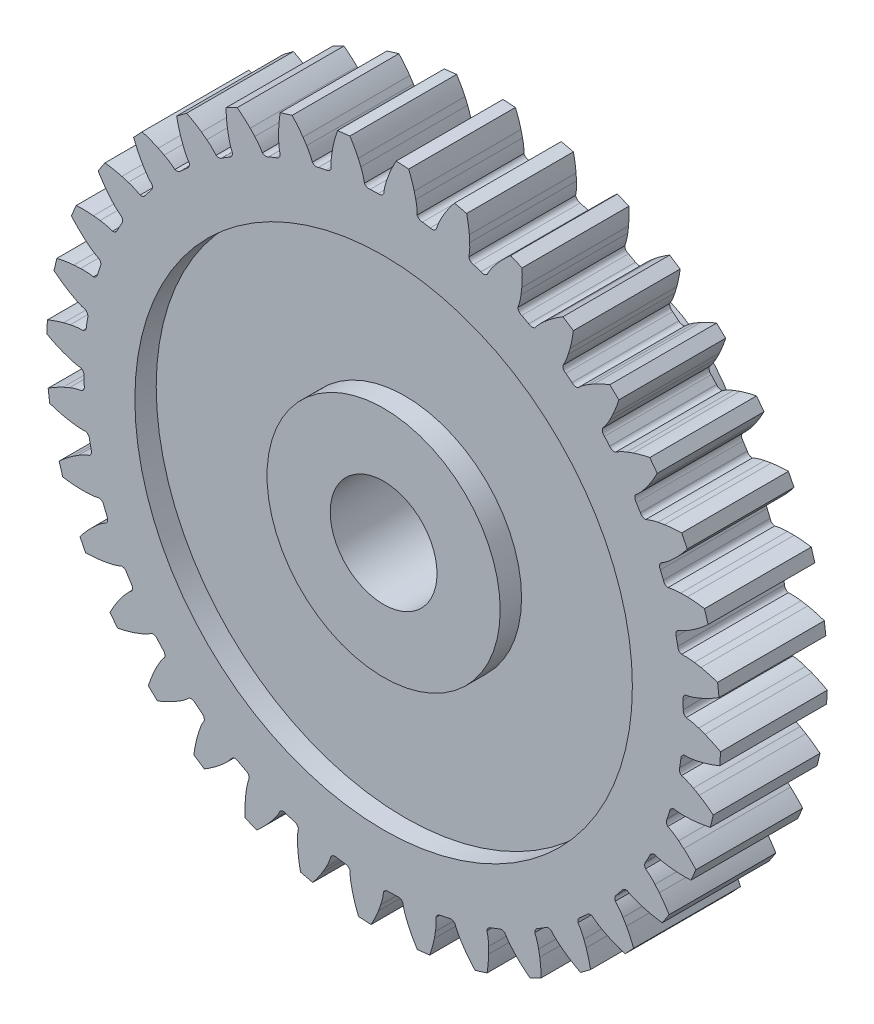
from build123d import *

# Parameters (mm, degrees)
MODEL_R             = 3.175
BOSS_EXTRUDE1_DEPTH = 6.35
SKETCH2_R           = 14.7955
SKETCH2_R_2         = 6.9342
CUT_EXTRUDE1_DEPTH  = 1.27
SKETCH3_R           = 14.7955
SKETCH3_R_2         = 7.62
CUT_EXTRUDE2_DEPTH  = 1.27
SKETCH4_R           = 7.62
SKETCH4_R_2         = 3.175
BOSS_EXTRUDE2_DEPTH = 7.62


with BuildPart() as part:
    # Model → Boss-Extrude1 (new body)
    with BuildSketch(Plane.XY):
        with BuildLine():
            Line((77.409149606, 88.38345564), (77.663315513, 88.690267015))
            ThreePointArc((77.663315513, 88.690267015), (78.015859422, 89.062022935), (78.39203915, 89.409842548))
            Line((78.39203915, 89.409842548), (79.073905257, 89.117654256))
            ThreePointArc((79.073905257, 89.117654256), (79.081524348, 88.605373453), (79.055509621, 88.09369689))
            Line((79.055509621, 88.09369689), (79.008657674, 87.698055906))
            ThreePointArc((79.008657674, 87.698055906), (78.940789963, 87.321747653), (78.828670449, 86.956175305))
            ThreePointArc((78.828670449, 86.956175305), (78.891320192, 86.770395671), (79.051204434, 86.656922803))
            Line((79.051204434, 86.656922803), (79.465600582, 86.434768475))
            ThreePointArc((79.465600582, 86.434768475), (79.648600627, 86.364421152), (79.837999893, 86.415073701))
            ThreePointArc((79.837999893, 86.415073701), (80.080401624, 86.71080376), (80.356239138, 86.975621684))
            Line((80.356239138, 86.975621684), (80.659815803, 87.233631048))
            ThreePointArc((80.659815803, 87.233631048), (81.071558515, 87.538520552), (81.50242147, 87.815733079))
            Line((81.50242147, 87.815733079), (82.123187177, 87.409579251))
            ThreePointArc((82.123187177, 87.409579251), (82.04173389, 86.903758104), (81.927262682, 86.404372467))
            Line((81.927262682, 86.404372467), (81.812425905, 86.022875741))
            ThreePointArc((81.812425905, 86.022875741), (81.680244015, 85.66406956), (81.506346876, 85.323520426))
            ThreePointArc((81.506346876, 85.323520426), (81.535786454, 85.12968568), (81.673537008, 84.990174454))
            Line((81.673537008, 84.990174454), (82.043052695, 84.699443515))
            ThreePointArc((82.043052695, 84.699443515), (82.211056874, 84.598387303), (82.406374462, 84.615381488))
            ThreePointArc((82.406374462, 84.615381488), (82.696446375, 84.864525792), (83.014078181, 85.077421622))
            Line((83.014078181, 85.077421622), (83.357840946, 85.27879979))
            ThreePointArc((83.357840946, 85.27879979), (83.816271868, 85.507558967), (84.288726497, 85.705741445))
            Line((84.288726497, 85.705741445), (84.829538787, 85.197958355))
            ThreePointArc((84.829538787, 85.197958355), (84.661488037, 84.713965983), (84.462038499, 84.242044852))
            Line((84.462038499, 84.242044852), (84.28270218, 83.886283232))
            ThreePointArc((84.28270218, 83.886283232), (84.090222391, 83.555881268), (83.859831404, 83.250702762))
            ThreePointArc((83.859831404, 83.250702762), (83.855166085, 83.054703598), (83.966596713, 82.893394416))
            Line((83.966596713, 82.893394416), (84.280018083, 82.542909385))
            ThreePointArc((84.280018083, 82.542909385), (84.427921674, 82.414214824), (84.623222958, 82.397034286))
            ThreePointArc((84.623222958, 82.397034286), (84.952151367, 82.592023042), (85.301926498, 82.746528287))
            Line((85.301926498, 82.746528287), (85.675439791, 82.885146559))
            ThreePointArc((85.675439791, 82.885146559), (86.166629732, 83.030824676), (86.666320739, 83.143955432))
            Line((86.666320739, 83.143955432), (87.110743193, 82.549979254))
            ThreePointArc((87.110743193, 82.549979254), (86.861201118, 82.10252152), (86.582833422, 81.672403981))
            Line((86.582833422, 81.672403981), (86.344435763, 81.353194507))
            ThreePointArc((86.344435763, 81.353194507), (86.097506475, 81.061235856), (85.817621954, 80.800700672))
            ThreePointArc((85.817621954, 80.800700672), (85.778990261, 80.608488118), (85.86071701, 80.430278095))
            Line((85.86071701, 80.430278095), (86.108518935, 80.030689944))
            ThreePointArc((86.108518935, 80.030689944), (86.231827962, 79.878267353), (86.421178811, 79.827434114))
            ThreePointArc((86.421178811, 79.827434114), (86.778968066, 79.962341881), (87.150257308, 80.053761542))
            Line((87.150257308, 80.053761542), (87.542169294, 80.125416917))
            ThreePointArc((87.542169294, 80.125416917), (88.051193695, 80.183587618), (88.562938223, 80.208229231))
            Line((88.562938223, 80.208229231), (88.897463323, 79.546103807))
            ThreePointArc((88.897463323, 79.546103807), (88.574012133, 79.148776488), (88.225184341, 78.773531444))
            Line((88.225184341, 78.773531444), (87.934983527, 78.50056402))
            ThreePointArc((87.934983527, 78.50056402), (87.641107562, 78.255919697), (87.320233656, 78.047944066))
            ThreePointArc((87.320233656, 78.047944066), (87.248813985, 77.865361877), (87.298353121, 77.675670289))
            Line((87.298353121, 77.675670289), (87.472999665, 77.239120879))
            ThreePointArc((87.472999665, 77.239120879), (87.567967446, 77.067601541), (87.745614531, 76.984660144))
            ThreePointArc((87.745614531, 76.984660144), (88.121396047, 77.055389462), (88.502920894, 77.080946748))
            Line((88.502920894, 77.080946748), (88.901325878, 77.083459706))
            ThreePointArc((88.901325878, 77.083459706), (89.41271829, 77.052355503), (89.92096724, 76.98775925))
            Line((89.92096724, 76.98775925), (90.135431937, 76.277603103))
            ThreePointArc((90.135431937, 76.277603103), (89.747899533, 75.942478788), (89.339210601, 75.63350787))
            Line((89.339210601, 75.63350787), (89.006015131, 75.415078001))
            ThreePointArc((89.006015131, 75.415078001), (88.674121761, 75.225181402), (88.322008061, 75.076084556))
            ThreePointArc((88.322008061, 75.076084556), (88.219971208, 74.908678426), (88.235818745, 74.71326812))
            Line((88.235818745, 74.71326812), (88.332002701, 74.253025985))
            ThreePointArc((88.332002701, 74.253025985), (88.395743688, 74.06762143), (88.556289293, 73.955092005))
            ThreePointArc((88.556289293, 73.955092005), (88.938644666, 73.959493121), (89.318812075, 73.918410986))
            Line((89.318812075, 73.918410986), (89.711596255, 73.851701439))
            ThreePointArc((89.711596255, 73.851701439), (90.20981828, 73.732267418), (90.699128765, 73.580396023))
            Line((90.699128765, 73.580396023), (90.787018694, 72.843792907))
            ThreePointArc((90.787018694, 72.843792907), (90.347180051, 72.58105418), (89.891047785, 72.347745312))
            Line((89.891047785, 72.347745312), (89.524986363, 72.190494357))
            ThreePointArc((89.524986363, 72.190494357), (89.165160001, 72.061115393), (88.792505304, 71.975427566))
            ThreePointArc((88.792505304, 71.975427566), (88.662943162, 71.828281525), (88.644615781, 71.63308313))
            Line((88.644615781, 71.63308313), (88.659423778, 71.163134507))
            ThreePointArc((88.659423778, 71.163134507), (88.690003504, 70.969490709), (88.828558454, 70.830798367))
            ThreePointArc((88.828558454, 70.830798367), (89.205867913, 70.768737275), (89.573124616, 70.662264176))
            Line((89.573124616, 70.662264176), (89.948356656, 70.528365369))
            ThreePointArc((89.948356656, 70.528365369), (90.418270069, 70.324230473), (90.873774637, 70.089698471))
            Line((90.873774637, 70.089698471), (90.83242255, 69.349015729))
            ThreePointArc((90.83242255, 69.349015729), (90.353641943, 69.166645771), (89.863925692, 69.016087927))
            Line((89.863925692, 69.016087927), (89.47612149, 68.924792014))
            ThreePointArc((89.47612149, 68.924792014), (89.099295278, 68.859861798), (88.717422507, 68.840186571))
            ThreePointArc((88.717422507, 68.840186571), (88.564275546, 68.717775768), (88.512330004, 68.528725359))
            Line((88.512330004, 68.528725359), (88.44531154, 68.063340247))
            ThreePointArc((88.44531154, 68.063340247), (88.441796382, 67.867316253), (88.554172572, 67.706663353))
            ThreePointArc((88.554172572, 67.706663353), (88.914969915, 67.580026485), (89.258155416, 67.411398694))
            Line((89.258155416, 67.411398694), (89.604438768, 67.214379509))
            ThreePointArc((89.604438768, 67.214379509), (90.031765488, 66.931746273), (90.439623863, 66.621679801))
            Line((90.439623863, 66.621679801), (90.270280006, 65.899432014))
            ThreePointArc((90.270280006, 65.899432014), (89.767104941, 65.802972046), (89.258684485, 65.739739848))
            Line((89.258684485, 65.739739848), (88.860918298, 65.717173697))
            ThreePointArc((88.860918298, 65.717173697), (88.478541909, 65.718665102), (88.099054076, 65.765600297))
            ThreePointArc((88.099054076, 65.765600297), (87.926979225, 65.671641448), (87.842995655, 65.494483948))
            Line((87.842995655, 65.494483948), (87.696174889, 65.047814961))
            ThreePointArc((87.696174889, 65.047814961), (87.658673925, 64.855379413), (87.741445785, 64.677653271))
            ThreePointArc((87.741445785, 64.677653271), (88.074775852, 64.490287008), (88.383469465, 64.264625086))
            Line((88.383469465, 64.264625086), (88.690280841, 64.010466808))
            ThreePointArc((88.690280841, 64.010466808), (89.06203676, 63.657922899), (89.409856373, 63.281743171))
            Line((89.409856373, 63.281743171), (89.117668081, 62.599873249))
            ThreePointArc((89.117668081, 62.599873249), (88.605387279, 62.592254158), (88.093710716, 62.618268885))
            Line((88.093710716, 62.618268885), (87.698069731, 62.665120833))
            ThreePointArc((87.698069731, 62.665120833), (87.321761479, 62.732988543), (86.95618913, 62.845108057))
            ThreePointArc((86.95618913, 62.845108057), (86.770409496, 62.782458314), (86.656936629, 62.622574072))
            Line((86.656936629, 62.622574072), (86.4347823, 62.208181739))
            ThreePointArc((86.4347823, 62.208181739), (86.364434977, 62.025181693), (86.415087526, 61.835782428))
            ThreePointArc((86.415087526, 61.835782428), (86.710818718, 61.593380027), (86.975637591, 61.31754162))
            Line((86.975637591, 61.31754162), (87.233646955, 61.01396877))
            ThreePointArc((87.233646955, 61.01396877), (87.53853646, 60.602226058), (87.815748986, 60.171363103))
            Line((87.815748986, 60.171363103), (87.409595158, 59.550593581))
            ThreePointArc((87.409595158, 59.550593581), (86.903774011, 59.632046869), (86.404388374, 59.746518076))
            Line((86.404388374, 59.746518076), (86.022891648, 59.861354854))
            ThreePointArc((86.022891648, 59.861354854), (85.664085468, 59.993536744), (85.323536334, 60.167433882))
            ThreePointArc((85.323536334, 60.167433882), (85.129702403, 60.137994719), (84.990191727, 60.000244843))
            Line((84.990191727, 60.000244843), (84.699460788, 59.630725342))
            ThreePointArc((84.699460788, 59.630725342), (84.598404575, 59.462721162), (84.61539876, 59.267403575))
            ThreePointArc((84.61539876, 59.267403575), (84.864543064, 58.977331662), (85.077438894, 58.659699856))
            Line((85.077438894, 58.659699856), (85.278817063, 58.315933276))
            ThreePointArc((85.278817063, 58.315933276), (85.507576239, 57.857502354), (85.705758718, 57.385047725))
            Line((85.705758718, 57.385047725), (85.197975628, 56.84423925))
            ThreePointArc((85.197975628, 56.84423925), (84.713983255, 57.012289999), (84.242062125, 57.211739537))
            Line((84.242062125, 57.211739537), (83.886300504, 57.391075856))
            ThreePointArc((83.886300504, 57.391075856), (83.55589854, 57.583555645), (83.250720034, 57.813946632))
            ThreePointArc((83.250720034, 57.813946632), (83.054721395, 57.818612526), (82.893412522, 57.707182348))
            Line((82.893412522, 57.707182348), (82.542927491, 57.393760979))
            ThreePointArc((82.542927491, 57.393760979), (82.41423293, 57.245857388), (82.397052392, 57.050556103))
            ThreePointArc((82.397052392, 57.050556103), (82.592041148, 56.721627695), (82.746546393, 56.371852564))
            Line((82.746546393, 56.371852564), (82.885164665, 55.99833927))
            ThreePointArc((82.885164665, 55.99833927), (83.030842782, 55.50714933), (83.143973538, 55.007458322))
            Line((83.143973538, 55.007458322), (82.54999736, 54.563035869))
            ThreePointArc((82.54999736, 54.563035869), (82.102539626, 54.812577943), (81.672422087, 55.090945639))
            Line((81.672422087, 55.090945639), (81.353212613, 55.329339483))
            ThreePointArc((81.353212613, 55.329339483), (81.061253962, 55.576268771), (80.800718778, 55.856153293))
            ThreePointArc((80.800718778, 55.856153293), (80.608505918, 55.894784163), (80.43029589, 55.813057093))
            Line((80.43029589, 55.813057093), (80.03070774, 55.565258984))
            ThreePointArc((80.03070774, 55.565258984), (79.878285149, 55.441949957), (79.82745191, 55.252599107))
            ThreePointArc((79.82745191, 55.252599107), (79.962359676, 54.894809852), (80.053779338, 54.52352061))
            Line((80.053779338, 54.52352061), (80.125434713, 54.131608624))
            ThreePointArc((80.125434713, 54.131608624), (80.183605413, 53.622584223), (80.208247026, 53.110839695))
            Line((80.208247026, 53.110839695), (79.546121602, 52.776310781))
            ThreePointArc((79.546121602, 52.776310781), (79.148794283, 53.099761971), (78.773549239, 53.448589762))
            Line((78.773549239, 53.448589762), (78.500581815, 53.738794391))
            ThreePointArc((78.500581815, 53.738794391), (78.255937493, 54.032670356), (78.047961861, 54.353544262))
            ThreePointArc((78.047961861, 54.353544262), (77.865379487, 54.424962802), (77.675688224, 54.375423364))
            Line((77.675688224, 54.375423364), (77.239138814, 54.20077682))
            ThreePointArc((77.239138814, 54.20077682), (77.067619477, 54.10580904), (76.984678079, 53.928161954))
            ThreePointArc((76.984678079, 53.928161954), (77.055406721, 53.552382247), (77.08096377, 53.17085929))
            Line((77.08096377, 53.17085929), (77.083476728, 52.772458121))
            ThreePointArc((77.083476728, 52.772458121), (77.052372525, 52.261065708), (76.987776272, 51.752816758))
            Line((76.987776272, 51.752816758), (76.277620124, 51.538348247))
            ThreePointArc((76.277620124, 51.538348247), (75.942495809, 51.925880651), (75.633524891, 52.334569583))
            Line((75.633524891, 52.334569583), (75.415095023, 52.667761238))
            ThreePointArc((75.415095023, 52.667761238), (75.225198423, 52.999654608), (75.076101578, 53.351768308))
            ThreePointArc((75.076101578, 53.351768308), (74.908695626, 53.453806624), (74.713284677, 53.437959483))
            Line((74.713284677, 53.437959483), (74.253042542, 53.341771712))
            ThreePointArc((74.253042542, 53.341771712), (74.067637987, 53.278030726), (73.955108562, 53.117485121))
            ThreePointArc((73.955108562, 53.117485121), (73.959509316, 52.73513166), (73.918427274, 52.354966166))
            Line((73.918427274, 52.354966166), (73.851717727, 51.962181986))
            ThreePointArc((73.851717727, 51.962181986), (73.732283707, 51.463959962), (73.580412312, 50.974649477))
            Line((73.580412312, 50.974649477), (72.843809196, 50.886755733))
            ThreePointArc((72.843809196, 50.886755733), (72.581070468, 51.326594376), (72.347761601, 51.782726642))
            Line((72.347761601, 51.782726642), (72.190510646, 52.148788064))
            ThreePointArc((72.190510646, 52.148788064), (72.061131681, 52.508614426), (71.975443854, 52.881269123))
            ThreePointArc((71.975443854, 52.881269123), (71.828298098, 53.010833042), (71.633098795, 53.029161016))
            Line((71.633098795, 53.029161016), (71.163150171, 53.01435302))
            ThreePointArc((71.163150171, 53.01435302), (70.969493822, 52.983775565), (70.830795521, 52.845209538))
            ThreePointArc((70.830795521, 52.845209538), (70.768734429, 52.467900079), (70.66226133, 52.100643376))
            Line((70.66226133, 52.100643376), (70.528362523, 51.725411336))
            ThreePointArc((70.528362523, 51.725411336), (70.324227626, 51.255497923), (70.089695625, 50.799993355))
            Line((70.089695625, 50.799993355), (69.349012882, 50.841345442))
            ThreePointArc((69.349012882, 50.841345442), (69.166642925, 51.320126049), (69.01608508, 51.8098423))
            Line((69.01608508, 51.8098423), (68.924789168, 52.197650317))
            ThreePointArc((68.924789168, 52.197650317), (68.859858952, 52.574476529), (68.840183725, 52.9563493))
            ThreePointArc((68.840183725, 52.9563493), (68.717771938, 53.109492192), (68.528723709, 53.16143599))
            Line((68.528723709, 53.16143599), (68.063338597, 53.228462084))
            ThreePointArc((68.063338597, 53.228462084), (67.867314603, 53.231977242), (67.706661703, 53.119601052))
            ThreePointArc((67.706661703, 53.119601052), (67.580027832, 52.758800249), (67.411402349, 52.415611084))
            Line((67.411402349, 52.415611084), (67.214375942, 52.06932803))
            ThreePointArc((67.214375942, 52.06932803), (66.931742706, 51.642001311), (66.621676234, 51.234142935))
            Line((66.621676234, 51.234142935), (65.899428447, 51.403486792))
            ThreePointArc((65.899428447, 51.403486792), (65.802968479, 51.906661857), (65.739736281, 52.415082313))
            Line((65.739736281, 52.415082313), (65.71717013, 52.812852315))
            ThreePointArc((65.71717013, 52.812852315), (65.718661536, 53.195228704), (65.76559673, 53.574716537))
            ThreePointArc((65.76559673, 53.574716537), (65.671637106, 53.746789182), (65.494480772, 53.830771558))
            Line((65.494480772, 53.830771558), (65.047811786, 53.977592324))
            ThreePointArc((65.047811786, 53.977592324), (64.855376237, 54.015093288), (64.677650095, 53.932321428))
            ThreePointArc((64.677650095, 53.932321428), (64.490284355, 53.598992917), (64.264623303, 53.290300666))
            Line((64.264623303, 53.290300666), (64.010465025, 52.98348929))
            ThreePointArc((64.010465025, 52.98348929), (63.657921116, 52.611733371), (63.281741387, 52.263913758))
            Line((63.281741387, 52.263913758), (62.599871466, 52.55610205))
            ThreePointArc((62.599871466, 52.55610205), (62.592252375, 53.068382852), (62.618267102, 53.580059416))
            Line((62.618267102, 53.580059416), (62.66511905, 53.975704214))
            ThreePointArc((62.66511905, 53.975704214), (62.73298676, 54.352012467), (62.845106274, 54.717584816))
            ThreePointArc((62.845106274, 54.717584816), (62.782454331, 54.903359907), (62.622572344, 55.016829729))
            Line((62.622572344, 55.016829729), (62.208180011, 55.238984058))
            ThreePointArc((62.208180011, 55.238984058), (62.025179965, 55.30933138), (61.8357807, 55.258678831))
            ThreePointArc((61.8357807, 55.258678831), (61.593378978, 54.962948904), (61.317541524, 54.698131072))
            Line((61.317541524, 54.698131072), (61.013968674, 54.440117894))
            ThreePointArc((61.013968674, 54.440117894), (60.602225962, 54.135228389), (60.171363006, 53.858015862))
            Line((60.171363006, 53.858015862), (59.550593485, 54.26416969))
            ThreePointArc((59.550593485, 54.26416969), (59.632046772, 54.769990838), (59.74651798, 55.269376474))
            Line((59.74651798, 55.269376474), (59.861354757, 55.650877015))
            ThreePointArc((59.861354757, 55.650877015), (59.993536648, 56.009683196), (60.167433786, 56.35023233))
            ThreePointArc((60.167433786, 56.35023233), (60.137993196, 56.544064039), (60.000244298, 56.683572897))
            Line((60.000244298, 56.683572897), (59.630724797, 56.974311465))
            ThreePointArc((59.630724797, 56.974311465), (59.462720617, 57.075367678), (59.26740303, 57.058373493))
            ThreePointArc((59.26740303, 57.058373493), (58.977331117, 56.809229189), (58.65969931, 56.596333358))
            Line((58.65969931, 56.596333358), (58.315932731, 56.39495519))
            ThreePointArc((58.315932731, 56.39495519), (57.857501808, 56.166196014), (57.38504718, 55.968013535))
            Line((57.38504718, 55.968013535), (56.844238704, 56.475788996))
            ThreePointArc((56.844238704, 56.475788996), (57.012289454, 56.959781369), (57.211738992, 57.431702499))
            Line((57.211738992, 57.431702499), (57.391075311, 57.787464119))
            ThreePointArc((57.391075311, 57.787464119), (57.5835551, 58.117866083), (57.813946087, 58.423044589))
            ThreePointArc((57.813946087, 58.423044589), (57.818613698, 58.61904529), (57.707182784, 58.780356209))
            Line((57.707182784, 58.780356209), (57.393761414, 59.13084124))
            ThreePointArc((57.393761414, 59.13084124), (57.245857823, 59.259535801), (57.050556539, 59.276716339))
            ThreePointArc((57.050556539, 59.276716339), (56.721628788, 59.081728196), (56.371854435, 58.927223364))
            Line((56.371854435, 58.927223364), (55.998341142, 58.788601277))
            ThreePointArc((55.998341142, 58.788601277), (55.507151202, 58.64292316), (55.007460194, 58.529792404))
            Line((55.007460194, 58.529792404), (54.56303774, 59.123764767))
            ThreePointArc((54.56303774, 59.123764767), (54.812579815, 59.571222501), (55.090947511, 60.00134004))
            Line((55.090947511, 60.00134004), (55.329341355, 60.320553329))
            ThreePointArc((55.329341355, 60.320553329), (55.576270643, 60.61251198), (55.856155164, 60.873047164))
            ThreePointArc((55.856155164, 60.873047164), (55.894786035, 61.065260024), (55.813058965, 61.243470051))
            Line((55.813058965, 61.243470051), (55.565260855, 61.643054387))
            ThreePointArc((55.565260855, 61.643054387), (55.441951828, 61.795476979), (55.252600979, 61.846310218))
            ThreePointArc((55.252600979, 61.846310218), (54.894812208, 61.711402782), (54.523523507, 61.619983302))
            Line((54.523523507, 61.619983302), (54.131611521, 61.548327926))
            ThreePointArc((54.131611521, 61.548327926), (53.62258712, 61.490157226), (53.110842592, 61.465515613))
            Line((53.110842592, 61.465515613), (52.776313677, 62.127637222))
            ThreePointArc((52.776313677, 62.127637222), (53.099764868, 62.524964542), (53.448592659, 62.900209585))
            Line((53.448592659, 62.900209585), (53.738797288, 63.173177009))
            ThreePointArc((53.738797288, 63.173177009), (54.032673253, 63.417821332), (54.353547159, 63.625796964))
            ThreePointArc((54.353547159, 63.625796964), (54.424967755, 63.808380842), (54.375428215, 63.9980743))
            Line((54.375428215, 63.9980743), (54.200781671, 64.43462371))
            ThreePointArc((54.200781671, 64.43462371), (54.105813891, 64.606143048), (53.928166805, 64.689084445))
            ThreePointArc((53.928166805, 64.689084445), (53.552387098, 64.618355803), (53.170864141, 64.592798755))
            Line((53.170864141, 64.592798755), (52.772462972, 64.590285796))
            ThreePointArc((52.772462972, 64.590285796), (52.261070559, 64.621389999), (51.752821609, 64.685986253))
            Line((51.752821609, 64.685986253), (51.538353098, 65.3961424))
            ThreePointArc((51.538353098, 65.3961424), (51.925885502, 65.731266715), (52.334574434, 66.040237633))
            Line((52.334574434, 66.040237633), (52.667766089, 66.258663687))
            ThreePointArc((52.667766089, 66.258663687), (52.999659459, 66.448560286), (53.351773159, 66.597657132))
            ThreePointArc((53.351773159, 66.597657132), (53.453813539, 66.765064257), (53.437966613, 66.960477306))
            Line((53.437966613, 66.960477306), (53.341778842, 67.420719441))
            ThreePointArc((53.341778842, 67.420719441), (53.278037855, 67.606123996), (53.117492251, 67.718653421))
            ThreePointArc((53.117492251, 67.718653421), (52.735138789, 67.714252667), (52.354973296, 67.755334709))
            Line((52.354973296, 67.755334709), (51.962189116, 67.822044256))
            ThreePointArc((51.962189116, 67.822044256), (51.463967091, 67.941478276), (50.974656606, 68.093349671))
            Line((50.974656606, 68.093349671), (50.886762862, 68.829956602))
            ThreePointArc((50.886762862, 68.829956602), (51.326601506, 69.09269533), (51.782733771, 69.326004197))
            Line((51.782733771, 69.326004197), (52.148795193, 69.483251337))
            ThreePointArc((52.148795193, 69.483251337), (52.508621555, 69.612630302), (52.881276253, 69.698318129))
            ThreePointArc((52.881276253, 69.698318129), (53.010840171, 69.845463885), (53.029168146, 70.040663188))
            Line((53.029168146, 70.040663188), (53.014360149, 70.510611812))
            ThreePointArc((53.014360149, 70.510611812), (52.983782695, 70.704268161), (52.845216668, 70.842966462))
            ThreePointArc((52.845216668, 70.842966462), (52.467907209, 70.905027554), (52.100650505, 71.011500653))
            Line((52.100650505, 71.011500653), (51.725418465, 71.145403275))
            ThreePointArc((51.725418465, 71.145403275), (51.255505053, 71.349538171), (50.800000485, 71.584070173))
            Line((50.800000485, 71.584070173), (50.841352571, 72.324749101))
            ThreePointArc((50.841352571, 72.324749101), (51.320133179, 72.507119058), (51.80984943, 72.657676903))
            Line((51.80984943, 72.657676903), (52.197657446, 72.748972815))
            ThreePointArc((52.197657446, 72.748972815), (52.574483659, 72.813903031), (52.956356429, 72.833578258))
            ThreePointArc((52.956356429, 72.833578258), (53.109499321, 72.955990045), (53.161443119, 73.145038274))
            Line((53.161443119, 73.145038274), (53.228469214, 73.610423386))
            ThreePointArc((53.228469214, 73.610423386), (53.231984372, 73.80644738), (53.119608181, 73.96710028))
            ThreePointArc((53.119608181, 73.96710028), (52.758807283, 74.093737701), (52.415618512, 74.262366856))
            Line((52.415618512, 74.262366856), (52.069335159, 74.459386041))
            ThreePointArc((52.069335159, 74.459386041), (51.64200844, 74.742019277), (51.234150065, 75.052085749))
            Line((51.234150065, 75.052085749), (51.403493922, 75.774333536))
            ThreePointArc((51.403493922, 75.774333536), (51.906668987, 75.870793504), (52.415089443, 75.934025702))
            Line((52.415089443, 75.934025702), (52.812859444, 75.956591853))
            ThreePointArc((52.812859444, 75.956591853), (53.195235834, 75.955100448), (53.574723666, 75.908165253))
            ThreePointArc((53.574723666, 75.908165253), (53.746796311, 76.002124877), (53.830778687, 76.179281211))
            Line((53.830778687, 76.179281211), (53.977599453, 76.625950198))
            ThreePointArc((53.977599453, 76.625950198), (54.015100417, 76.818385746), (53.932328557, 76.996111888))
            ThreePointArc((53.932328557, 76.996111888), (53.599001023, 77.18347725), (53.290309639, 77.40913773))
            Line((53.290309639, 77.40913773), (52.983498263, 77.663303638))
            ThreePointArc((52.983498263, 77.663303638), (52.611742343, 78.015847546), (52.263922731, 78.392027275))
            Line((52.263922731, 78.392027275), (52.556111022, 79.073893382))
            ThreePointArc((52.556111022, 79.073893382), (53.068391825, 79.081512473), (53.580068388, 79.055497746))
            Line((53.580068388, 79.055497746), (53.975713187, 79.008645798))
            ThreePointArc((53.975713187, 79.008645798), (54.35202144, 78.940778088), (54.717593788, 78.828658574))
            ThreePointArc((54.717593788, 78.828658574), (54.903368879, 78.891310517), (55.016838701, 79.051192504))
            Line((55.016838701, 79.051192504), (55.23899303, 79.465588652))
            ThreePointArc((55.23899303, 79.465588652), (55.309340352, 79.648588697), (55.258687804, 79.837987963))
            ThreePointArc((55.258687804, 79.837987963), (54.962959009, 80.080389014), (54.698142127, 80.356225576))
            Line((54.698142127, 80.356225576), (54.440128948, 80.659802241))
            ThreePointArc((54.440128948, 80.659802241), (54.135239444, 81.071544953), (53.858026917, 81.502407908))
            Line((53.858026917, 81.502407908), (54.264180745, 82.123173615))
            ThreePointArc((54.264180745, 82.123173615), (54.770001892, 82.041720328), (55.269387529, 81.92724912))
            Line((55.269387529, 81.92724912), (55.65088807, 81.812412343))
            ThreePointArc((55.65088807, 81.812412343), (56.00969425, 81.680230452), (56.350243384, 81.506333314))
            ThreePointArc((56.350243384, 81.506333314), (56.544075909, 81.535774319), (56.683585317, 81.673523895))
            Line((56.683585317, 81.673523895), (56.974323885, 82.043039581))
            ThreePointArc((56.974323885, 82.043039581), (57.075380098, 82.211043761), (57.058385912, 82.406361349))
            ThreePointArc((57.058385912, 82.406361349), (56.809241608, 82.696433261), (56.596345778, 83.014065068))
            Line((56.596345778, 83.014065068), (56.39496761, 83.357827833))
            ThreePointArc((56.39496761, 83.357827833), (56.166208433, 83.816258755), (55.968025955, 84.288713384))
            Line((55.968025955, 84.288713384), (56.475801416, 84.829525674))
            ThreePointArc((56.475801416, 84.829525674), (56.959793788, 84.661474924), (57.431714918, 84.462025386))
            Line((57.431714918, 84.462025386), (57.787476539, 84.282689067))
            ThreePointArc((57.787476539, 84.282689067), (58.117878503, 84.090209278), (58.423057009, 83.859818291))
            ThreePointArc((58.423057009, 83.859818291), (58.619058235, 83.855151254), (58.780369463, 83.96658262))
            Line((58.780369463, 83.96658262), (59.130854493, 84.280003989))
            ThreePointArc((59.130854493, 84.280003989), (59.259549055, 84.42790758), (59.276729592, 84.623208864))
            ThreePointArc((59.276729592, 84.623208864), (59.081741449, 84.952136615), (58.927236617, 85.301910968))
            Line((58.927236617, 85.301910968), (58.78861453, 85.675424261))
            ThreePointArc((58.78861453, 85.675424261), (58.642936414, 86.166614202), (58.529805657, 86.666305209))
            Line((58.529805657, 86.666305209), (59.12377802, 87.110727663))
            ThreePointArc((59.12377802, 87.110727663), (59.571235755, 86.861185588), (60.001353293, 86.582817892))
            Line((60.001353293, 86.582817892), (60.320566582, 86.344420233))
            ThreePointArc((60.320566582, 86.344420233), (60.612525233, 86.097490945), (60.873060417, 85.817606424))
            ThreePointArc((60.873060417, 85.817606424), (61.065272971, 85.778974731), (61.243482994, 85.86070148))
            Line((61.243482994, 85.86070148), (61.64306733, 86.108503405))
            ThreePointArc((61.64306733, 86.108503405), (61.795489921, 86.231812432), (61.84632316, 86.421163281))
            ThreePointArc((61.84632316, 86.421163281), (61.711415725, 86.778952052), (61.619996244, 87.150240753))
            Line((61.619996244, 87.150240753), (61.548340869, 87.542152739))
            ThreePointArc((61.548340869, 87.542152739), (61.490170169, 88.05117714), (61.465528556, 88.562921668))
            Line((61.465528556, 88.562921668), (62.127650165, 88.897446768))
            ThreePointArc((62.127650165, 88.897446768), (62.524977484, 88.573995578), (62.900222528, 88.225167786))
            Line((62.900222528, 88.225167786), (63.173189952, 87.934966972))
            ThreePointArc((63.173189952, 87.934966972), (63.417834274, 87.641091007), (63.625809906, 87.320217101))
            ThreePointArc((63.625809906, 87.320217101), (63.808393599, 87.248795373), (63.998087383, 87.298334612))
            Line((63.998087383, 87.298334612), (64.434636793, 87.472981156))
            ThreePointArc((64.434636793, 87.472981156), (64.60615613, 87.567948937), (64.689097528, 87.745596022))
            ThreePointArc((64.689097528, 87.745596022), (64.618368209, 88.121377538), (64.592810923, 88.502902385))
            Line((64.592810923, 88.502902385), (64.590297965, 88.901307368))
            ThreePointArc((64.590297965, 88.901307368), (64.621402168, 89.412699781), (64.685998422, 89.920948731))
            Line((64.685998422, 89.920948731), (65.396154569, 90.135413428))
            ThreePointArc((65.396154569, 90.135413428), (65.731278884, 89.747881023), (66.040249802, 89.339192092))
            Line((66.040249802, 89.339192092), (66.258675855, 89.005996622))
            ThreePointArc((66.258675855, 89.005996622), (66.448572455, 88.674103252), (66.597669301, 88.321989552))
            ThreePointArc((66.597669301, 88.321989552), (66.765076604, 88.219950635), (66.96048901, 88.235797957))
            Line((66.96048901, 88.235797957), (67.420731145, 88.331981914))
            ThreePointArc((67.420731145, 88.331981914), (67.606135701, 88.3957229), (67.718665125, 88.556268505))
            ThreePointArc((67.718665125, 88.556268505), (67.714264009, 88.938623878), (67.755346144, 89.318791287))
            Line((67.755346144, 89.318791287), (67.822055691, 89.711575467))
            ThreePointArc((67.822055691, 89.711575467), (67.941489712, 90.209797492), (68.093361107, 90.699107977))
            Line((68.093361107, 90.699107977), (68.829968038, 90.786997906))
            ThreePointArc((68.829968038, 90.786997906), (69.092706765, 90.347159263), (69.326015633, 89.891026997))
            Line((69.326015633, 89.891026997), (69.483262773, 89.524965575))
            ThreePointArc((69.483262773, 89.524965575), (69.612641738, 89.165139213), (69.698329565, 88.792484516))
            ThreePointArc((69.698329565, 88.792484516), (69.845475606, 88.662922374), (70.040674, 88.644594994))
            Line((70.040674, 88.644594994), (70.510622624, 88.65940299))
            ThreePointArc((70.510622624, 88.65940299), (70.704278973, 88.689980445), (70.842977274, 88.828546472))
            ThreePointArc((70.842977274, 88.828546472), (70.905038366, 89.205855931), (71.011511465, 89.573112634))
            Line((71.011511465, 89.573112634), (71.145414087, 89.948344674))
            ThreePointArc((71.145414087, 89.948344674), (71.349548983, 90.418258087), (71.584080985, 90.873762655))
            Line((71.584080985, 90.873762655), (72.324759913, 90.832410568))
            ThreePointArc((72.324759913, 90.832410568), (72.50712987, 90.353629961), (72.657687715, 89.86391371))
            Line((72.657687715, 89.86391371), (72.748983627, 89.476109508))
            ThreePointArc((72.748983627, 89.476109508), (72.813913843, 89.099283295), (72.83358907, 88.717410525))
            ThreePointArc((72.83358907, 88.717410525), (72.955999873, 88.564263563), (73.145050282, 88.512318022))
            Line((73.145050282, 88.512318022), (73.610435394, 88.445299557))
            ThreePointArc((73.610435394, 88.445299557), (73.806459388, 88.441784399), (73.967112288, 88.55416059))
            ThreePointArc((73.967112288, 88.55416059), (74.093745395, 88.914959786), (74.262369725, 89.258147547))
            Line((74.262369725, 89.258147547), (74.459396132, 89.604426786))
            ThreePointArc((74.459396132, 89.604426786), (74.742029369, 90.031753505), (75.05209584, 90.439611881))
            Line((75.05209584, 90.439611881), (75.774343627, 90.270268024))
            ThreePointArc((75.774343627, 90.270268024), (75.870803595, 89.767092959), (75.934035794, 89.258672503))
            Line((75.934035794, 89.258672503), (75.956601944, 88.860906316))
            ThreePointArc((75.956601944, 88.860906316), (75.955110539, 88.478529927), (75.908175345, 88.099042094))
            ThreePointArc((75.908175345, 88.099042094), (76.002134193, 87.926967242), (76.179291693, 87.842983672))
            Line((76.179291693, 87.842983672), (76.62596068, 87.696162907))
            ThreePointArc((76.62596068, 87.696162907), (76.818396228, 87.658661942), (76.99612237, 87.741433802))
            ThreePointArc((76.99612237, 87.741433802), (77.183488255, 88.074762893), (77.409149606, 88.38345564))
        make_face()
        with Locations((70.836883545, 70.836883545)):
            Circle(MODEL_R, mode=Mode.SUBTRACT)
    extrude(amount=BOSS_EXTRUDE1_DEPTH)

    # Sketch2 → Cut-Extrude1 (cut)
    with BuildSketch(Plane.XY.offset(6.35)):
        with Locations((70.836883545, 70.836883545)):
            Circle(SKETCH2_R)
        with Locations((70.836883545, 70.836883545)):
            Circle(SKETCH2_R_2, mode=Mode.SUBTRACT)
    extrude(amount=-CUT_EXTRUDE1_DEPTH, mode=Mode.SUBTRACT)

    # Sketch3 → Cut-Extrude2 (cut)
    with BuildSketch(Plane(origin=(0, 0, 0), x_dir=(-1, 0, 0), z_dir=(0, 0, -1))):
        with Locations(Location((-70.836883545, 70.836883545, 0), (0, 0, 180))):  # turned: the seam where the file's is
            Circle(SKETCH3_R)
        with Locations((-70.836883545, 70.836883545)):
            Circle(SKETCH3_R_2, mode=Mode.SUBTRACT)
    extrude(amount=-CUT_EXTRUDE2_DEPTH, mode=Mode.SUBTRACT)

    # Sketch4 → Boss-Extrude2 (add)
    with BuildSketch(Plane(origin=(0, 0, 0), x_dir=(-1, 0, 0), z_dir=(0, 0, -1))):
        with Locations((-70.836883545, 70.836883545)):
            Circle(SKETCH4_R)
        with Locations((-70.836883545, 70.836883545)):
            Circle(SKETCH4_R_2, mode=Mode.SUBTRACT)
    extrude(amount=BOSS_EXTRUDE2_DEPTH)


solid = part.part
